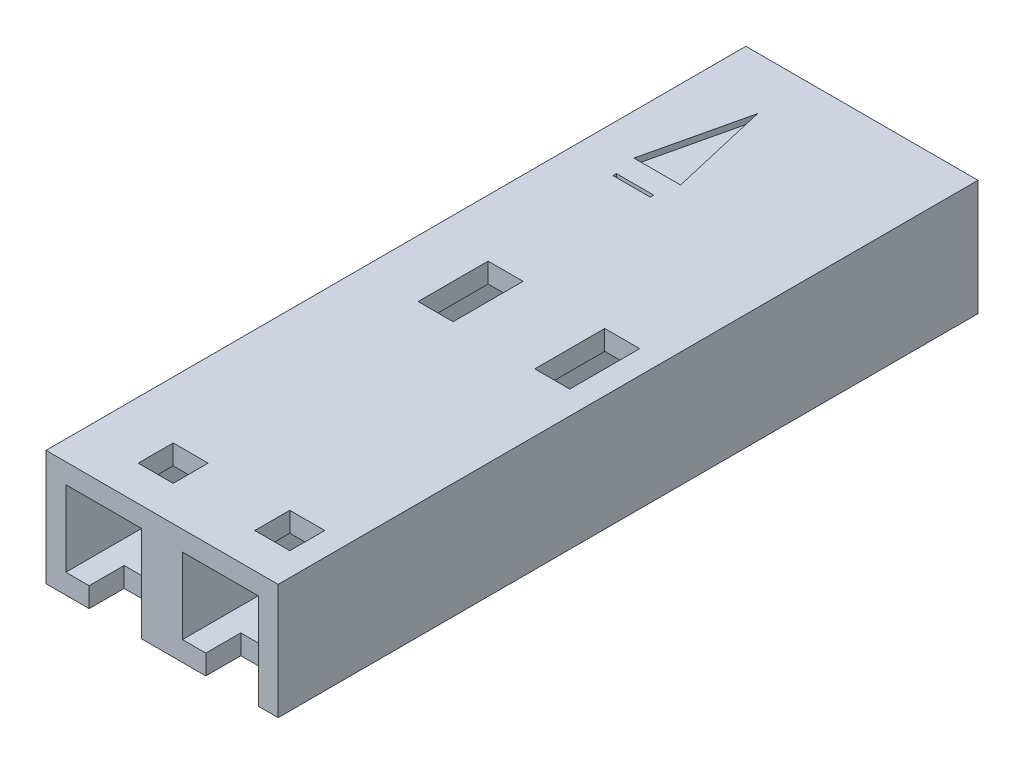
from build123d import *

# Parameters (mm, degrees)
SKETCH1_W           = 5.0546
SKETCH1_H           = 2.5146
BOSS_EXTRUDE1_DEPTH = 15.24
SKETCH2_W           = 1.143
SKETCH2_H           = 1.143
CUT_EXTRUDE1_DEPTH  = 16.24
CHAMFER1_SIZE       = 0.254
SKETCH3_W           = 0.762
SKETCH3_H           = 0.762
SKETCH3_H_2         = 1.524
CUT_EXTRUDE2_DEPTH  = 1.27
SKETCH4_W           = 1.651
SKETCH4_H           = 1.651
CUT_EXTRUDE3_DEPTH  = 15.732
SKETCH6_W           = 1.143
SKETCH6_H           = 0.762
CUT_EXTRUDE5_DEPTH  = 0.4318
SKETCH7_W           = 0.508
SKETCH7_H           = 7.62
CUT_EXTRUDE6_DEPTH  = 0.762
SKETCH8_W           = 0.8128
SKETCH8_H           = 0.0762
CUT_EXTRUDE7_DEPTH  = 0.127


with BuildPart() as part:
    # Sketch1 → Boss-Extrude1 (new body)
    with BuildSketch(Plane.XY):
        with Locations((2.5273, 1.2573)):
            Rectangle(SKETCH1_W, SKETCH1_H)
    extrude(amount=BOSS_EXTRUDE1_DEPTH)

    # Sketch2 → Cut-Extrude1 (cut, through all)
    with BuildSketch(Plane(origin=(0, 0, 0), x_dir=(-1, 0, 0), z_dir=(0, 0, -1))):
        with Locations((-3.7973, 1.2573)):
            Rectangle(SKETCH2_W, SKETCH2_H)
        with Locations((-1.2573, 1.2573)):
            Rectangle(SKETCH2_W, SKETCH2_H)
    extrude(amount=-CUT_EXTRUDE1_DEPTH, mode=Mode.SUBTRACT)

    # Chamfer1
    chamfer1_edges = [part.edges().sort_by_distance(p)[0] for p in [
        (4.3688, 1.2573, 0),
        (3.7973, 0.6858, 0),
        (3.2258, 1.2573, 0),
        (3.7973, 1.8288, 0),
        (1.8288, 1.2573, 0),
        (1.2573, 0.6858, 0),
        (0.6858, 1.2573, 0),
        (1.2573, 1.8288, 0),
    ]]
    chamfer(chamfer1_edges, length=CHAMFER1_SIZE)

    # Sketch3 → Cut-Extrude2 (cut)
    with BuildSketch(Plane(origin=(0, 2.5146, 0), x_dir=(1, 0, 0), z_dir=(0, 1, 0))):
        with Locations((4.1656, -14.097)):
            Rectangle(SKETCH3_W, SKETCH3_H)
        with Locations((1.6256, -14.097)):
            Rectangle(SKETCH3_W, SKETCH3_H)
        with Locations((4.1656, -7.62)):
            Rectangle(SKETCH3_W, SKETCH3_H_2)
        with Locations((1.6256, -7.62)):
            Rectangle(SKETCH3_W, SKETCH3_H_2)
    extrude(amount=-CUT_EXTRUDE2_DEPTH, mode=Mode.SUBTRACT)

    # Sketch4 → Cut-Extrude3 (cut, through all)
    with BuildSketch(Plane.XY.offset(0.508)):
        with Locations((1.2573, 1.2573)):
            Rectangle(SKETCH4_W, SKETCH4_H)
        with Locations((3.7973, 1.2573)):
            Rectangle(SKETCH4_W, SKETCH4_H)
    extrude(amount=CUT_EXTRUDE3_DEPTH, mode=Mode.SUBTRACT)

    # Sketch6 → Cut-Extrude5 (cut)
    with BuildSketch(Plane.XZ):
        with Locations((1.5113, 14.859)):
            Rectangle(SKETCH6_W, SKETCH6_H)
        with Locations((4.0513, 14.859)):
            Rectangle(SKETCH6_W, SKETCH6_H)
    extrude(amount=-CUT_EXTRUDE5_DEPTH, mode=Mode.SUBTRACT)

    # Sketch7 → Cut-Extrude6 (cut)
    with BuildSketch(Plane.XZ):
        with Locations((2.4638, 3.81)):
            Rectangle(SKETCH7_W, SKETCH7_H)
    extrude(amount=-CUT_EXTRUDE6_DEPTH, mode=Mode.SUBTRACT)

    # Sketch8 → Cut-Extrude7 (cut)
    with BuildSketch(Plane(origin=(0, 2.5146, 0), x_dir=(1, 0, 0), z_dir=(0, 1, 0))):
        Polygon((1.397, -1.143), (0.889, -3.3274), (1.905, -3.3274), align=None)
        with Locations((1.397, -3.8481)):
            Rectangle(SKETCH8_W, SKETCH8_H)
    extrude(amount=-CUT_EXTRUDE7_DEPTH, mode=Mode.SUBTRACT)


solid = part.part
